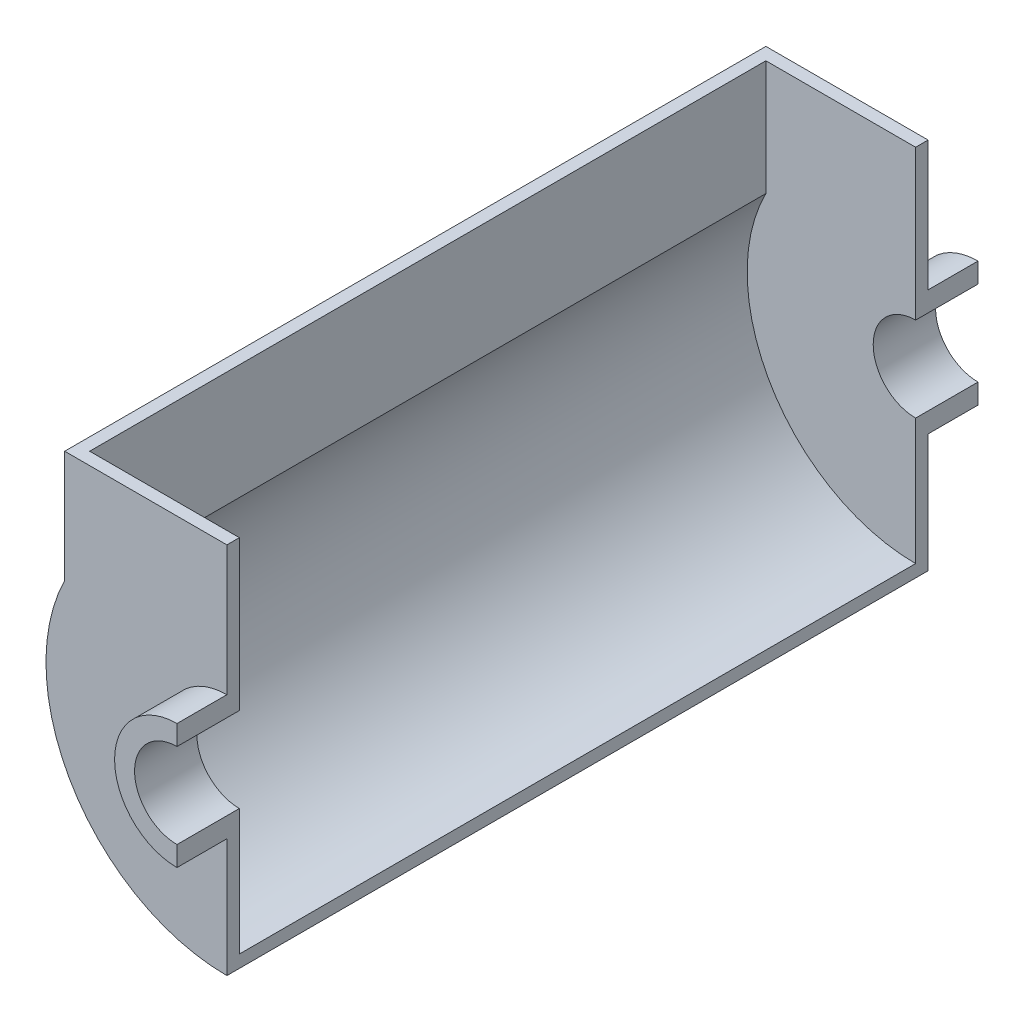
from build123d import *

# Parameters (mm, degrees)
BOSS_EXTRUDE1_DEPTH      = 20
BOSS_EXTRUDE1_DEPTH_BACK = 5
BOSS_EXTRUDE2_DEPTH      = 5
BOSS_EXTRUDE3_DEPTH      = 271


with BuildPart() as part:
    # Sketch1 → Boss-Extrude1 (new body, two sides)
    with BuildSketch(Plane.XY) as boss_extrude1_sk:
        with BuildLine():
            Line((0, 25), (0, 17))
            ThreePointArc((0, 17), (-17, 0), (0, -17))
            Line((0, -17), (0, -25))
            ThreePointArc((0, -25), (-25, 0), (0, 25))
        make_face()
    extrude(amount=BOSS_EXTRUDE1_DEPTH)
    extrude(boss_extrude1_sk.sketch, amount=-BOSS_EXTRUDE1_DEPTH_BACK)

    # Sketch2 → Boss-Extrude2 (add)
    with BuildSketch(Plane.XY):
        with BuildLine():
            Line((0, 25), (0, 77))
            Line((0, 77), (-65, 77))
            Line((-65, 77), (-65, 32.113081447))
            ThreePointArc((-65, 32.113081447), (-61.581037686, -38.262590053), (0, -72.5))
            Line((0, -72.5), (0, -25))
            ThreePointArc((0, -25), (-25, 0), (0, 25))
        make_face()
    extrude(amount=-BOSS_EXTRUDE2_DEPTH)


with BuildPart() as body_2:
    # Mirror5: mirrored copy
    add(part.part.mirror(Plane.XY.offset(-140.5)))


with BuildPart() as part_1:
    add(part.part)

    add(body_2.part)  # Boss-Extrude3 merges body 2
    # Sketch3 → Boss-Extrude3 (add)
    with BuildSketch(Plane(origin=(0, 0, -5), x_dir=(-1, 0, 0), z_dir=(0, 0, -1))):
        with BuildLine():
            Line((65, 77), (65, 32.113081447))
            ThreePointArc((65, 32.113081447), (61.581037686, -38.262590053), (0, -72.5))
            Line((0, -72.5), (0, -67.5))
            ThreePointArc((0, -67.5), (57.634938288, -35.134938288), (60, 30.923292192))
            Line((60, 30.923292192), (60, 77))
            Line((60, 77), (65, 77))
        make_face()
    extrude(amount=BOSS_EXTRUDE3_DEPTH)


solid = part_1.part
